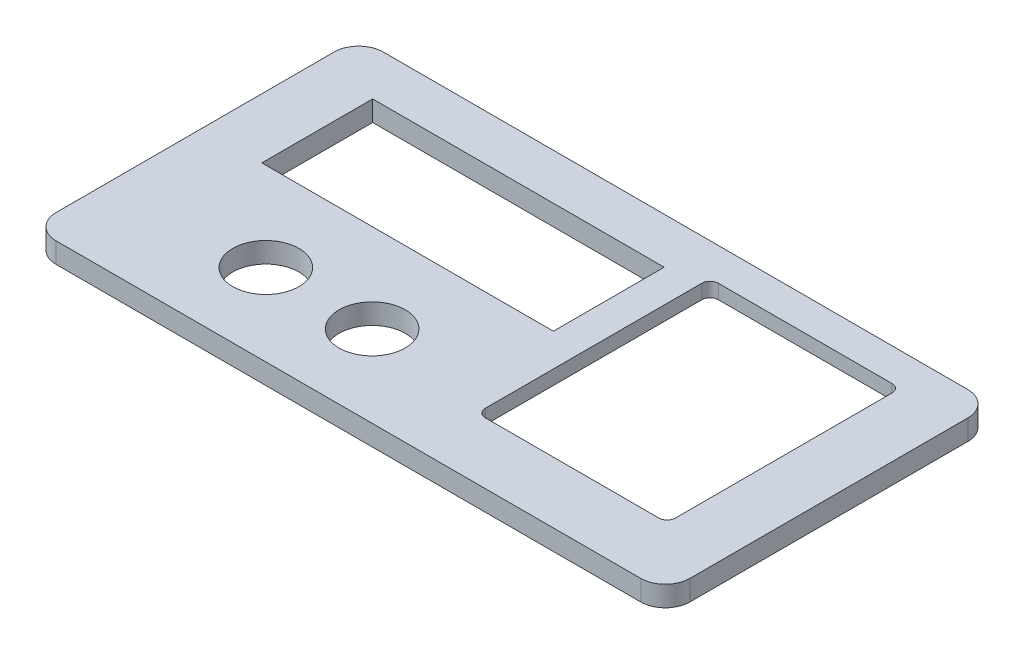
from build123d import *

# Parameters (mm, degrees)
SKETCH1_W                = 155
SKETCH1_H                = 80
BOSS_EXTRUDE1_DEPTH      = 5
SKETCH2_W                = 71.2978
SKETCH2_H                = 27.1018
SCREEN_CUTOUT_DEPTH      = 88.357026048
SKETCH2_3_R              = 1.5
SKETCH2_3_W              = 71.2978
SKETCH2_3_H              = 27.1018
CUT_EXTRUDE4_DEPTH       = 2.9
SKETCH3_R                = 8.1
ULTRASOUND_CUTOUTS_DEPTH = 88.357026048
SKETCH3_3_R              = 8.1
SKETCH3_3_R_2            = 1.190625
CUT_EXTRUDE2_DEPTH       = 3.175
SKETCH5_W                = 12
SKETCH5_H                = 5
US_CLOCK_CUTOUT_DEPTH    = 4
SKETCH6_W                = 10
SKETCH6_H                = 3.5
US_PIN_CUTOUT_DEPTH      = 2
SKETCH9_R                = 3.15
MAGNET_HOLES_DEPTH       = 2.1
FILLET1_R                = 6
SKETCH10_W               = 46.5
SKETCH10_H               = 57
KEYPAD_CUTOUT_DEPTH      = 88.357026048
CUT_EXTRUDE1_DEPTH       = 1.5
FILLET3_R                = 2
FILLET4_R                = 2
SKETCH12_R               = 1.5
CUT_EXTRUDE3_DEPTH       = 2.9


with BuildPart() as part:
    # Sketch1 → Boss-Extrude1 (new body)
    with BuildSketch(Plane(origin=(0, 0, 0), x_dir=(1, 0, 0), z_dir=(0, 1, 0))):
        Rectangle(SKETCH1_W, SKETCH1_H)
    extrude(amount=BOSS_EXTRUDE1_DEPTH)

    # Sketch2 → Screen Cutout (cut, through all)
    with BuildSketch(Plane(origin=(0, 0, 0), x_dir=(1, 0, 0), z_dir=(0, 1, 0))):
        with Locations((-27.2029, 15.22)):
            Rectangle(SKETCH2_W, SKETCH2_H)
    extrude(amount=SCREEN_CUTOUT_DEPTH, mode=Mode.SUBTRACT)

    # Sketch2_3 → Cut-Extrude4 (cut)
    with BuildSketch(Plane(origin=(0, 0, 0), x_dir=(1, 0, 0), z_dir=(0, 1, 0))):
        with Locations((-64.96, -0.02)):
            Circle(SKETCH2_3_R)
        with Locations((9.97, -0.02)):
            Circle(SKETCH2_3_R)
        with Locations((9.97, 30.46)):
            Circle(SKETCH2_3_R)
        with Locations((-64.96, 30.46)):
            Circle(SKETCH2_3_R)
        with Locations((-27.2029, 15.22)):
            Rectangle(SKETCH2_3_W, SKETCH2_3_H)
    extrude(amount=CUT_EXTRUDE4_DEPTH, mode=Mode.SUBTRACT)

    # Sketch3 → Ultrasound Cutouts (cut, through all)
    with BuildSketch(Plane(origin=(0, 0, 0), x_dir=(1, 0, 0), z_dir=(0, 1, 0))):
        with Locations((-40.2029, -20)):
            Circle(SKETCH3_R)
        with Locations((-14.2029, -20)):
            Circle(SKETCH3_R)
    extrude(amount=ULTRASOUND_CUTOUTS_DEPTH, mode=Mode.SUBTRACT)

    # Sketch3_3 → Cut-Extrude2 (cut)
    with BuildSketch(Plane(origin=(0, 0, 0), x_dir=(1, 0, 0), z_dir=(0, 1, 0))):
        with Locations((-40.2029, -20)):
            Circle(SKETCH3_3_R)
        with Locations((-14.2029, -20)):
            Circle(SKETCH3_3_R)
        with Locations((-48.3529, -11.45)):
            Circle(SKETCH3_3_R_2)
        with Locations((-6.0529, -11.45)):
            Circle(SKETCH3_3_R_2)
        with Locations((-6.0529, -28.55)):
            Circle(SKETCH3_3_R_2)
        with Locations((-48.3529, -28.55)):
            Circle(SKETCH3_3_R_2)
    extrude(amount=CUT_EXTRUDE2_DEPTH, mode=Mode.SUBTRACT)

    # Sketch5 → US Clock cutout (cut)
    with BuildSketch(Plane.XZ):
        with Locations((-27.471992442, 27.55)):
            Rectangle(SKETCH5_W, SKETCH5_H)
    extrude(amount=-US_CLOCK_CUTOUT_DEPTH, mode=Mode.SUBTRACT)

    # Sketch6 → US Pin cutout (cut)
    with BuildSketch(Plane.XZ):
        with Locations((-27.471992442, 11.55)):
            Rectangle(SKETCH6_W, SKETCH6_H)
    extrude(amount=-US_PIN_CUTOUT_DEPTH, mode=Mode.SUBTRACT)

    # Sketch9 → Magnet Holes (cut)
    with BuildSketch(Plane(origin=(0, 0.2, 0), x_dir=(-1, 0, 0), z_dir=(0, -1, 0))):
        with Locations((-71.5, 34)):
            Circle(SKETCH9_R)
        with Locations((71.5, 34)):
            Circle(SKETCH9_R)
        with Locations((-71.5, -34)):
            Circle(SKETCH9_R)
        with Locations((71.5, -34)):
            Circle(SKETCH9_R)
    extrude(amount=-MAGNET_HOLES_DEPTH, mode=Mode.SUBTRACT)

    # Fillet1
    fillet1_edges = [part.edges().sort_by_distance(p)[0] for p in [
        (77.5, 2.5, -40),
        (77.5, 2.5, 40),
        (-77.5, 2.5, 40),
        (-77.5, 2.5, -40),
    ]]
    fillet(fillet1_edges, radius=FILLET1_R)

    # Sketch10 → Keypad cutout (cut, through all)
    with BuildSketch(Plane(origin=(0, 5, 0), x_dir=(1, 0, 0), z_dir=(0, 1, 0))):
        with Locations((39.696, 3.5)):
            Rectangle(SKETCH10_W, SKETCH10_H)
    extrude(amount=-KEYPAD_CUTOUT_DEPTH, mode=Mode.SUBTRACT)

    # Sketch11 → Cut-Extrude1 (cut)
    with BuildSketch(Plane.XZ):
        Polygon((58.696, 28.5), (58.696, 34.5), (20.696, 34.5), (20.696, 28.5), (13.696, 28.5), (13.696, -35.5), (65.696, -35.5), (65.696, 28.5), align=None)
    extrude(amount=-CUT_EXTRUDE1_DEPTH, mode=Mode.SUBTRACT)

    # Fillet3
    fillet3_edges = [part.edges().sort_by_distance(p)[0] for p in [
        (65.696, 0.75, 28.5),
        (13.696, 0.75, 28.5),
        (13.696, 0.75, -35.5),
        (65.696, 0.75, -35.5),
    ]]
    fillet(fillet3_edges, radius=FILLET3_R)

    # Fillet4
    fillet4_edges = [part.edges().sort_by_distance(p)[0] for p in [
        (62.946, 3.25, 25),
        (16.446, 3.25, 25),
        (16.446, 3.25, -32),
        (62.946, 3.25, -32),
    ]]
    fillet(fillet4_edges, radius=FILLET4_R)

    # Sketch12 → Cut-Extrude3 (cut)
    with BuildSketch(Plane.XZ.offset(-1.5)):
        with Locations((63.092012723, -34.123666466)):
            Circle(SKETCH12_R)
        with Locations((15.839087894, -34.123666466)):
            Circle(SKETCH12_R)
        with Locations((15.839087894, 26.403006737)):
            Circle(SKETCH12_R)
        with Locations((63.092012723, 26.403006737)):
            Circle(SKETCH12_R)
    extrude(amount=-CUT_EXTRUDE3_DEPTH, mode=Mode.SUBTRACT)


solid = part.part
